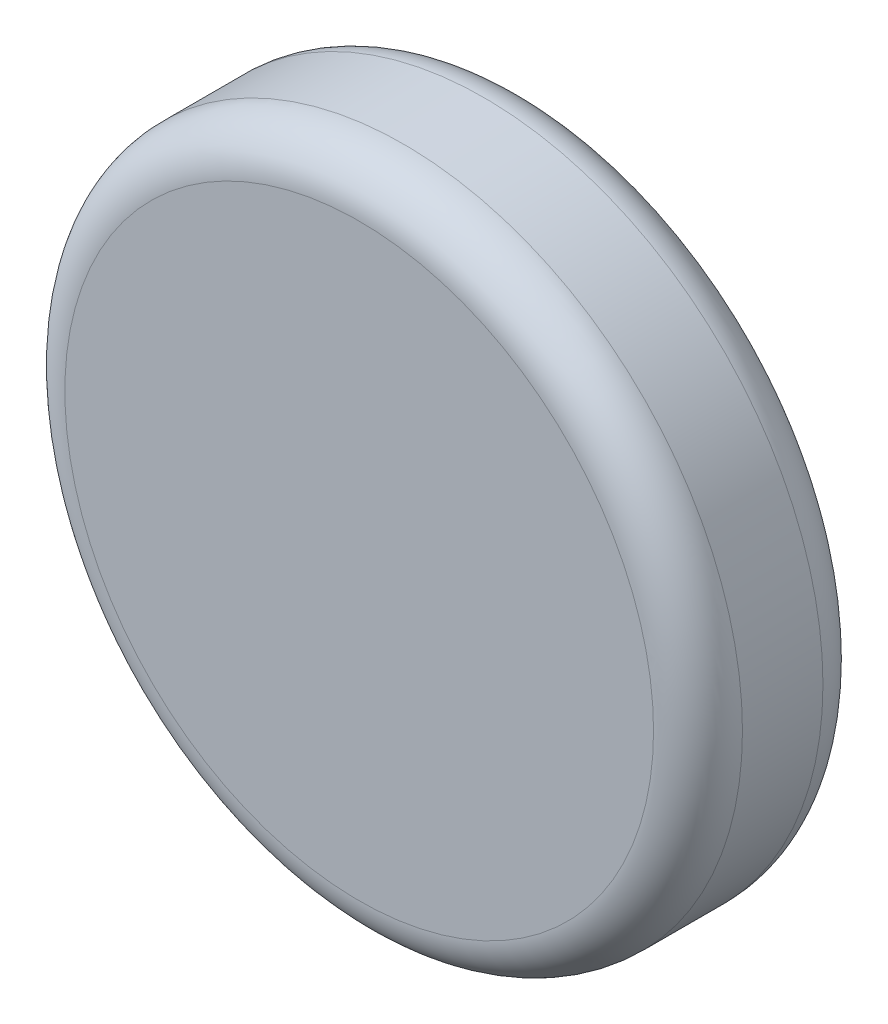
from build123d import *

# Parameters (mm, degrees)
SKETCH1_R               = 152.4
BOSS_EXTRUDE1_DEPTH     = 76.2
FILLET1_R               = 20
SKETCH2_R               = 15
SKETCH2_R_2             = 7.5
BOSS_EXTRUDE2_DEPTH     = 45
SKETCH4_R               = 3.1
CUT_EXTRUDE1_DEPTH      = 153.4
CUT_EXTRUDE1_DEPTH_BACK = 153.4


with BuildPart() as part:
    # Sketch1 → Boss-Extrude1 (new body)
    with BuildSketch(Plane.XY):
        Circle(SKETCH1_R)
    extrude(amount=BOSS_EXTRUDE1_DEPTH)

    # Fillet1
    fillet1_edges = [part.edges().sort_by_distance(p)[0] for p in [
        (-152.4, 0, 0),
        (-152.4, 0, 76.2),
    ]]
    fillet(fillet1_edges, radius=FILLET1_R)

    # Sketch2 → Boss-Extrude2 (add)
    with BuildSketch(Plane(origin=(0, 0, 0), x_dir=(-1, 0, 0), z_dir=(0, 0, -1))):
        Circle(SKETCH2_R)
        Circle(SKETCH2_R_2, mode=Mode.SUBTRACT)
    extrude(amount=BOSS_EXTRUDE2_DEPTH)

    # Sketch4 → Cut-Extrude1 (cut, two sides)
    with BuildSketch(Plane(origin=(0, 0, 0), x_dir=(0, 0, -1), z_dir=(1, 0, 0))) as cut_extrude1_sk:
        with Locations((30, 0)):
            Circle(SKETCH4_R)
    extrude(amount=CUT_EXTRUDE1_DEPTH, mode=Mode.SUBTRACT)
    extrude(cut_extrude1_sk.sketch, amount=-CUT_EXTRUDE1_DEPTH_BACK, mode=Mode.SUBTRACT)


solid = part.part
